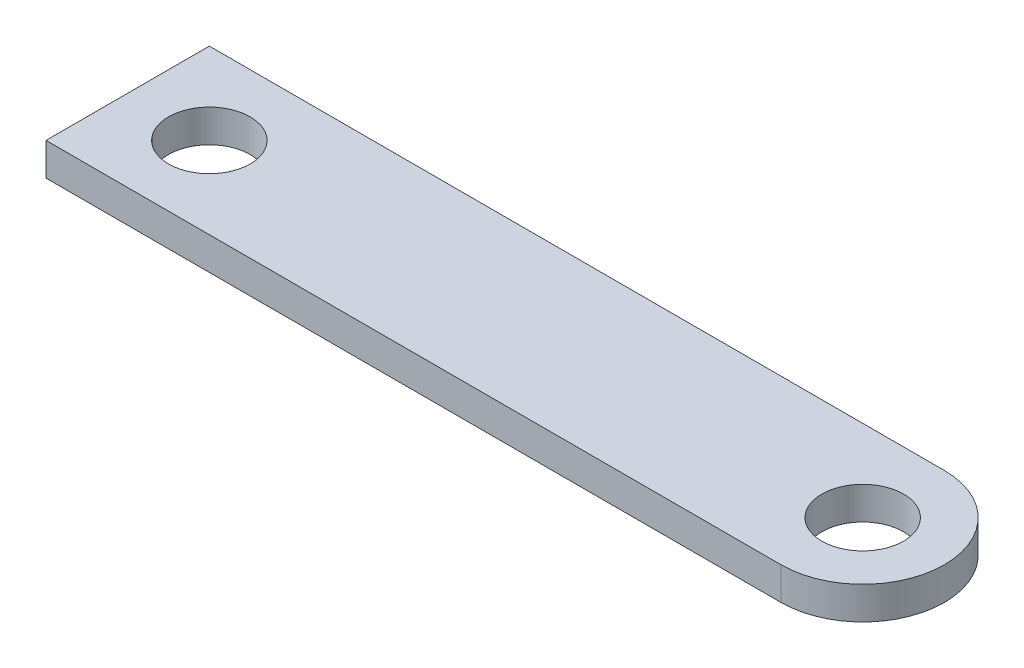
from build123d import *

# Parameters (mm, degrees)
CROQUIS1_R              = 2.5
SALIENTE_EXTRUIR2_DEPTH = 2


with BuildPart() as part:
    # Croquis1 → Saliente-Extruir2 (new body)
    with BuildSketch(Plane(origin=(0, 0, 0), x_dir=(1, 0, 0), z_dir=(0, 1, 0))):
        with BuildLine():
            Line((-22.5, 5), (-22.5, -5))
            Line((-22.5, -5), (22.5, -5))
            ThreePointArc((22.5, -5), (27.5, 0), (22.5, 5))
            Line((22.5, 5), (-22.5, 5))
        make_face()
        with Locations((22.5, 0)):
            Circle(CROQUIS1_R, mode=Mode.SUBTRACT)
        with Locations((-17.5, 0)):
            Circle(CROQUIS1_R, mode=Mode.SUBTRACT)
    extrude(amount=SALIENTE_EXTRUIR2_DEPTH)


solid = part.part
